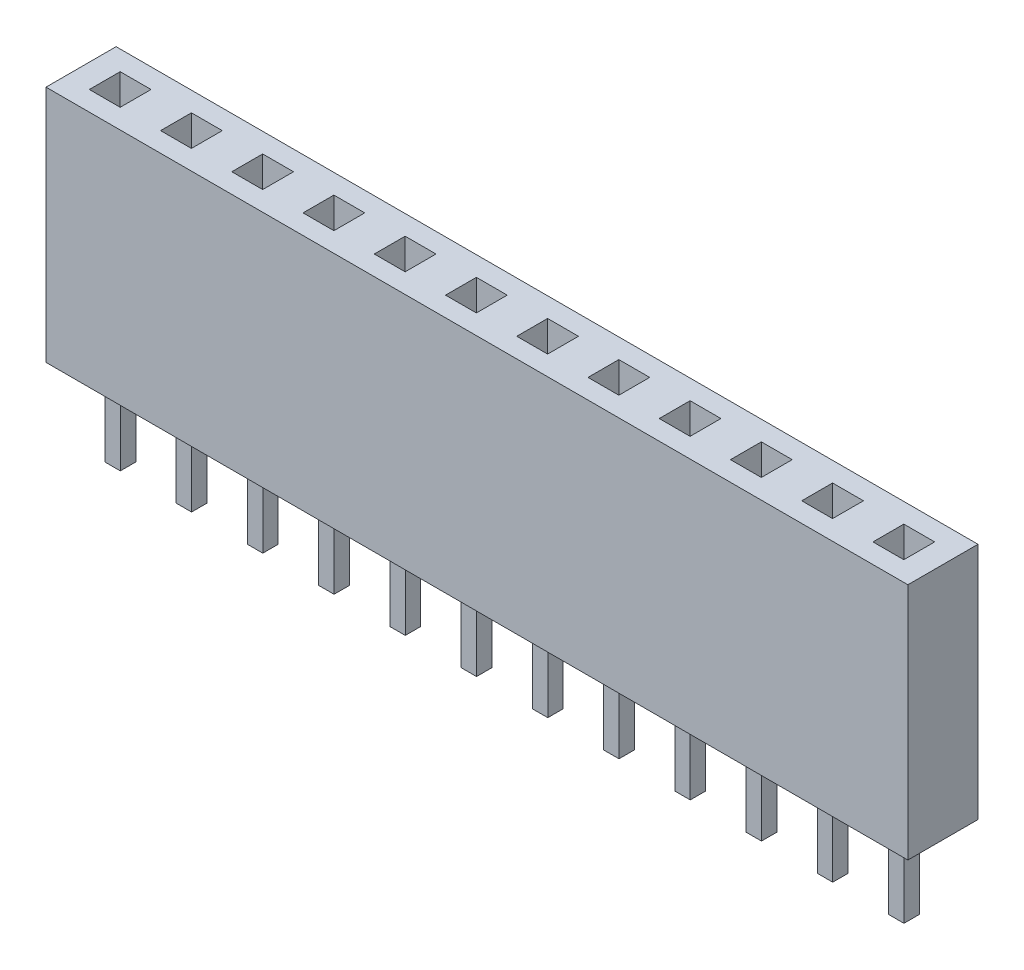
from build123d import *

# Parameters (mm, degrees)
SKETCH1_W              = 30.73
SKETCH1_H              = 8.5
BOSS_EXTRUDE1_DEPTH    = 1.25
SKETCH2_W              = 1.1
SKETCH2_H              = 1.1
CUT_EXTRUDE1_DEPTH     = 32.908390746
SKETCH3_W              = 30.73
SKETCH3_H              = 2.5
BOSS_EXTRUDE2_DEPTH    = 1
SKETCH4_W              = 0.55
SKETCH4_H              = 0.55
BOSS_EXTRUDE3_DEPTH    = 3
BOSS_EXTRUDE3_2_DEPTH  = 3
BOSS_EXTRUDE3_3_DEPTH  = 3
BOSS_EXTRUDE3_4_DEPTH  = 3
BOSS_EXTRUDE3_5_DEPTH  = 3
BOSS_EXTRUDE3_6_DEPTH  = 3
BOSS_EXTRUDE3_7_DEPTH  = 3
BOSS_EXTRUDE3_8_DEPTH  = 3
BOSS_EXTRUDE3_9_DEPTH  = 3
BOSS_EXTRUDE3_10_DEPTH = 3
BOSS_EXTRUDE3_11_DEPTH = 3
BOSS_EXTRUDE3_12_DEPTH = 3


with BuildPart() as part:
    # Sketch1 → Boss-Extrude1 (new, symmetric)
    with BuildSketch(Plane.XY):
        with Locations((15.365, 4.25)):
            Rectangle(SKETCH1_W, SKETCH1_H)
    extrude(amount=BOSS_EXTRUDE1_DEPTH, both=True)

    # Sketch2 → Cut-Extrude1 (cut, through all)
    with BuildSketch(Plane.XZ):
        with Locations((3.935, 0)):
            Rectangle(SKETCH2_W, SKETCH2_H)
        with Locations((1.395, 0)):
            Rectangle(SKETCH2_W, SKETCH2_H)
        with Locations((6.475, 0)):
            Rectangle(SKETCH2_W, SKETCH2_H)
        with Locations((9.015, 0)):
            Rectangle(SKETCH2_W, SKETCH2_H)
        with Locations((11.555, 0)):
            Rectangle(SKETCH2_W, SKETCH2_H)
        with Locations((14.095, 0)):
            Rectangle(SKETCH2_W, SKETCH2_H)
        with Locations((16.635, 0)):
            Rectangle(SKETCH2_W, SKETCH2_H)
        with Locations((19.175, 0)):
            Rectangle(SKETCH2_W, SKETCH2_H)
        with Locations((21.715, 0)):
            Rectangle(SKETCH2_W, SKETCH2_H)
        with Locations((24.255, 0)):
            Rectangle(SKETCH2_W, SKETCH2_H)
        with Locations((26.795, 0)):
            Rectangle(SKETCH2_W, SKETCH2_H)
        with Locations((29.335, 0)):
            Rectangle(SKETCH2_W, SKETCH2_H)
    extrude(amount=-CUT_EXTRUDE1_DEPTH, mode=Mode.SUBTRACT)

    # Sketch3 → Boss-Extrude2 (add)
    with BuildSketch(Plane.XZ):
        with Locations((15.365, 0)):
            Rectangle(SKETCH3_W, SKETCH3_H)
    extrude(amount=-BOSS_EXTRUDE2_DEPTH)


with BuildPart() as body_2:
    # Sketch4 → Boss-Extrude3 (new body)
    with BuildSketch(Plane.XZ):
        with Locations((1.4, 0)):
            Rectangle(SKETCH4_W, SKETCH4_H)
    extrude(amount=BOSS_EXTRUDE3_DEPTH)


with BuildPart() as body_3:
    # Sketch4 → Boss-Extrude3 2 (new body)
    with BuildSketch(Plane.XZ):
        with Locations((3.94, 0)):
            Rectangle(SKETCH4_W, SKETCH4_H)
    extrude(amount=BOSS_EXTRUDE3_2_DEPTH)


with BuildPart() as body_4:
    # Sketch4 → Boss-Extrude3 3 (new body)
    with BuildSketch(Plane.XZ):
        with Locations((6.48, 0)):
            Rectangle(SKETCH4_W, SKETCH4_H)
    extrude(amount=BOSS_EXTRUDE3_3_DEPTH)


with BuildPart() as body_5:
    # Sketch4 → Boss-Extrude3 4 (new body)
    with BuildSketch(Plane.XZ):
        with Locations((9.02, 0)):
            Rectangle(SKETCH4_W, SKETCH4_H)
    extrude(amount=BOSS_EXTRUDE3_4_DEPTH)


with BuildPart() as body_6:
    # Sketch4 → Boss-Extrude3 5 (new body)
    with BuildSketch(Plane.XZ):
        with Locations((11.56, 0)):
            Rectangle(SKETCH4_W, SKETCH4_H)
    extrude(amount=BOSS_EXTRUDE3_5_DEPTH)


with BuildPart() as body_7:
    # Sketch4 → Boss-Extrude3 6 (new body)
    with BuildSketch(Plane.XZ):
        with Locations((14.1, 0)):
            Rectangle(SKETCH4_W, SKETCH4_H)
    extrude(amount=BOSS_EXTRUDE3_6_DEPTH)


with BuildPart() as body_8:
    # Sketch4 → Boss-Extrude3 7 (new body)
    with BuildSketch(Plane.XZ):
        with Locations((16.64, 0)):
            Rectangle(SKETCH4_W, SKETCH4_H)
    extrude(amount=BOSS_EXTRUDE3_7_DEPTH)


with BuildPart() as body_9:
    # Sketch4 → Boss-Extrude3 8 (new body)
    with BuildSketch(Plane.XZ):
        with Locations((19.18, 0)):
            Rectangle(SKETCH4_W, SKETCH4_H)
    extrude(amount=BOSS_EXTRUDE3_8_DEPTH)


with BuildPart() as body_10:
    # Sketch4 → Boss-Extrude3 9 (new body)
    with BuildSketch(Plane.XZ):
        with Locations((21.72, 0)):
            Rectangle(SKETCH4_W, SKETCH4_H)
    extrude(amount=BOSS_EXTRUDE3_9_DEPTH)


with BuildPart() as body_11:
    # Sketch4 → Boss-Extrude3 10 (new body)
    with BuildSketch(Plane.XZ):
        with Locations((24.26, 0)):
            Rectangle(SKETCH4_W, SKETCH4_H)
    extrude(amount=BOSS_EXTRUDE3_10_DEPTH)


with BuildPart() as body_12:
    # Sketch4 → Boss-Extrude3 11 (new body)
    with BuildSketch(Plane.XZ):
        with Locations((26.8, 0)):
            Rectangle(SKETCH4_W, SKETCH4_H)
    extrude(amount=BOSS_EXTRUDE3_11_DEPTH)


with BuildPart() as body_13:
    # Sketch4 → Boss-Extrude3 12 (new body)
    with BuildSketch(Plane.XZ):
        with Locations((29.34, 0)):
            Rectangle(SKETCH4_W, SKETCH4_H)
    extrude(amount=BOSS_EXTRUDE3_12_DEPTH)


solid = Compound([part.part, body_2.part, body_3.part, body_4.part, body_5.part, body_6.part, body_7.part, body_8.part, body_9.part, body_10.part, body_11.part, body_12.part, body_13.part])
